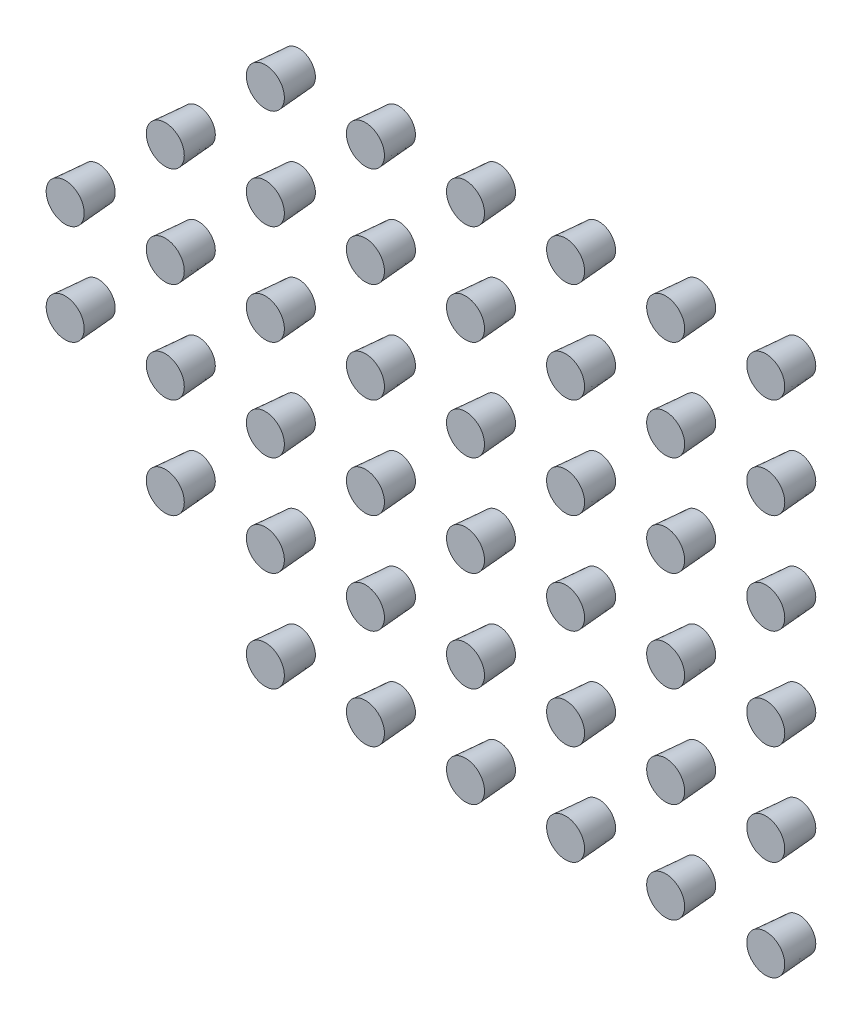
from build123d import *

# Parameters (mm, degrees)
SKETCH_1_R               = 0.5
EXTRUDE_1_DEPTH          = 1
EXTRUDE_1_TAPER          = -4
PATTERN_LINEAR_1_COUNT   = 6
PATTERN_LINEAR_1_PITCH   = 3
PATTERN_LINEAR_1_2_COUNT = 6
PATTERN_LINEAR_1_2_PITCH = 3
PATTERN_LINEAR_2_COUNT   = 2
PATTERN_LINEAR_2_PITCH   = 3
PATTERN_LINEAR_3_COUNT   = 2
PATTERN_LINEAR_3_PITCH   = 3


with BuildPart() as part:
    # 草图1 → 凸台-拉伸1 (new body)
    with BuildSketch(Plane.XY):
        Circle(SKETCH_1_R)
    extrude(amount=EXTRUDE_1_DEPTH, taper=EXTRUDE_1_TAPER)


with BuildPart() as pattern_linear_1_1:
    # 阵列(线性)1: pattern copy
    add(part.part.moved(Location(Vector(0, 1, 0) * (1 * PATTERN_LINEAR_1_PITCH))))


with BuildPart() as pattern_linear_1_2:
    # 阵列(线性)1: pattern copy
    add(part.part.moved(Location(Vector(0, 1, 0) * (2 * PATTERN_LINEAR_1_PITCH))))


with BuildPart() as pattern_linear_1_3:
    # 阵列(线性)1: pattern copy
    add(part.part.moved(Location(Vector(0, 1, 0) * (3 * PATTERN_LINEAR_1_PITCH))))


with BuildPart() as pattern_linear_1_4:
    # 阵列(线性)1: pattern copy
    add(part.part.moved(Location(Vector(0, 1, 0) * (4 * PATTERN_LINEAR_1_PITCH))))


with BuildPart() as pattern_linear_1_5:
    # 阵列(线性)1: pattern copy
    add(part.part.moved(Location(Vector(0, 1, 0) * (5 * PATTERN_LINEAR_1_PITCH))))


with BuildPart() as pattern_linear_1_2_1:
    # Pattern Linear 1 2: pattern copy
    add(part.part.moved(Location(Vector(1, 0, 0) * (1 * PATTERN_LINEAR_1_2_PITCH))))


with BuildPart() as pattern_linear_1_2_2:
    # Pattern Linear 1 2: pattern copy
    add(part.part.moved(Location(Vector(1, 0, 0) * (2 * PATTERN_LINEAR_1_2_PITCH))))


with BuildPart() as pattern_linear_1_2_3:
    # Pattern Linear 1 2: pattern copy
    add(part.part.moved(Location(Vector(1, 0, 0) * (3 * PATTERN_LINEAR_1_2_PITCH))))


with BuildPart() as pattern_linear_1_2_4:
    # Pattern Linear 1 2: pattern copy
    add(part.part.moved(Location(Vector(1, 0, 0) * (4 * PATTERN_LINEAR_1_2_PITCH))))


with BuildPart() as pattern_linear_1_2_5:
    # Pattern Linear 1 2: pattern copy
    add(part.part.moved(Location(Vector(1, 0, 0) * (5 * PATTERN_LINEAR_1_2_PITCH))))


with BuildPart() as pattern_linear_1_2_6:
    # Pattern Linear 1 2: pattern copy
    add(pattern_linear_1_1.part.moved(Location(Vector(1, 0, 0) * (1 * PATTERN_LINEAR_1_2_PITCH))))


with BuildPart() as pattern_linear_1_2_7:
    # Pattern Linear 1 2: pattern copy
    add(pattern_linear_1_1.part.moved(Location(Vector(1, 0, 0) * (2 * PATTERN_LINEAR_1_2_PITCH))))


with BuildPart() as pattern_linear_1_2_8:
    # Pattern Linear 1 2: pattern copy
    add(pattern_linear_1_1.part.moved(Location(Vector(1, 0, 0) * (3 * PATTERN_LINEAR_1_2_PITCH))))


with BuildPart() as pattern_linear_1_2_9:
    # Pattern Linear 1 2: pattern copy
    add(pattern_linear_1_1.part.moved(Location(Vector(1, 0, 0) * (4 * PATTERN_LINEAR_1_2_PITCH))))


with BuildPart() as pattern_linear_1_2_10:
    # Pattern Linear 1 2: pattern copy
    add(pattern_linear_1_1.part.moved(Location(Vector(1, 0, 0) * (5 * PATTERN_LINEAR_1_2_PITCH))))


with BuildPart() as pattern_linear_1_2_11:
    # Pattern Linear 1 2: pattern copy
    add(pattern_linear_1_2.part.moved(Location(Vector(1, 0, 0) * (1 * PATTERN_LINEAR_1_2_PITCH))))


with BuildPart() as pattern_linear_1_2_12:
    # Pattern Linear 1 2: pattern copy
    add(pattern_linear_1_2.part.moved(Location(Vector(1, 0, 0) * (2 * PATTERN_LINEAR_1_2_PITCH))))


with BuildPart() as pattern_linear_1_2_13:
    # Pattern Linear 1 2: pattern copy
    add(pattern_linear_1_2.part.moved(Location(Vector(1, 0, 0) * (3 * PATTERN_LINEAR_1_2_PITCH))))


with BuildPart() as pattern_linear_1_2_14:
    # Pattern Linear 1 2: pattern copy
    add(pattern_linear_1_2.part.moved(Location(Vector(1, 0, 0) * (4 * PATTERN_LINEAR_1_2_PITCH))))


with BuildPart() as pattern_linear_1_2_15:
    # Pattern Linear 1 2: pattern copy
    add(pattern_linear_1_2.part.moved(Location(Vector(1, 0, 0) * (5 * PATTERN_LINEAR_1_2_PITCH))))


with BuildPart() as pattern_linear_1_2_16:
    # Pattern Linear 1 2: pattern copy
    add(pattern_linear_1_3.part.moved(Location(Vector(1, 0, 0) * (1 * PATTERN_LINEAR_1_2_PITCH))))


with BuildPart() as pattern_linear_1_2_17:
    # Pattern Linear 1 2: pattern copy
    add(pattern_linear_1_3.part.moved(Location(Vector(1, 0, 0) * (2 * PATTERN_LINEAR_1_2_PITCH))))


with BuildPart() as pattern_linear_1_2_18:
    # Pattern Linear 1 2: pattern copy
    add(pattern_linear_1_3.part.moved(Location(Vector(1, 0, 0) * (3 * PATTERN_LINEAR_1_2_PITCH))))


with BuildPart() as pattern_linear_1_2_19:
    # Pattern Linear 1 2: pattern copy
    add(pattern_linear_1_3.part.moved(Location(Vector(1, 0, 0) * (4 * PATTERN_LINEAR_1_2_PITCH))))


with BuildPart() as pattern_linear_1_2_20:
    # Pattern Linear 1 2: pattern copy
    add(pattern_linear_1_3.part.moved(Location(Vector(1, 0, 0) * (5 * PATTERN_LINEAR_1_2_PITCH))))


with BuildPart() as pattern_linear_1_2_21:
    # Pattern Linear 1 2: pattern copy
    add(pattern_linear_1_4.part.moved(Location(Vector(1, 0, 0) * (1 * PATTERN_LINEAR_1_2_PITCH))))


with BuildPart() as pattern_linear_1_2_22:
    # Pattern Linear 1 2: pattern copy
    add(pattern_linear_1_4.part.moved(Location(Vector(1, 0, 0) * (2 * PATTERN_LINEAR_1_2_PITCH))))


with BuildPart() as pattern_linear_1_2_23:
    # Pattern Linear 1 2: pattern copy
    add(pattern_linear_1_4.part.moved(Location(Vector(1, 0, 0) * (3 * PATTERN_LINEAR_1_2_PITCH))))


with BuildPart() as pattern_linear_1_2_24:
    # Pattern Linear 1 2: pattern copy
    add(pattern_linear_1_4.part.moved(Location(Vector(1, 0, 0) * (4 * PATTERN_LINEAR_1_2_PITCH))))


with BuildPart() as pattern_linear_1_2_25:
    # Pattern Linear 1 2: pattern copy
    add(pattern_linear_1_4.part.moved(Location(Vector(1, 0, 0) * (5 * PATTERN_LINEAR_1_2_PITCH))))


with BuildPart() as pattern_linear_1_2_26:
    # Pattern Linear 1 2: pattern copy
    add(pattern_linear_1_5.part.moved(Location(Vector(1, 0, 0) * (1 * PATTERN_LINEAR_1_2_PITCH))))


with BuildPart() as pattern_linear_1_2_27:
    # Pattern Linear 1 2: pattern copy
    add(pattern_linear_1_5.part.moved(Location(Vector(1, 0, 0) * (2 * PATTERN_LINEAR_1_2_PITCH))))


with BuildPart() as pattern_linear_1_2_28:
    # Pattern Linear 1 2: pattern copy
    add(pattern_linear_1_5.part.moved(Location(Vector(1, 0, 0) * (3 * PATTERN_LINEAR_1_2_PITCH))))


with BuildPart() as pattern_linear_1_2_29:
    # Pattern Linear 1 2: pattern copy
    add(pattern_linear_1_5.part.moved(Location(Vector(1, 0, 0) * (4 * PATTERN_LINEAR_1_2_PITCH))))


with BuildPart() as pattern_linear_1_2_30:
    # Pattern Linear 1 2: pattern copy
    add(pattern_linear_1_5.part.moved(Location(Vector(1, 0, 0) * (5 * PATTERN_LINEAR_1_2_PITCH))))


with BuildPart() as pattern_linear_2_1:
    # 阵列(线性)2: pattern copy
    add(pattern_linear_1_4.part.moved(Location(Vector(-1, 0, 0) * (1 * PATTERN_LINEAR_2_PITCH))))


with BuildPart() as pattern_linear_2_2:
    # 阵列(线性)2: pattern copy
    add(pattern_linear_1_3.part.moved(Location(Vector(-1, 0, 0) * (1 * PATTERN_LINEAR_2_PITCH))))


with BuildPart() as pattern_linear_2_3:
    # 阵列(线性)2: pattern copy
    add(pattern_linear_1_2.part.moved(Location(Vector(-1, 0, 0) * (1 * PATTERN_LINEAR_2_PITCH))))


with BuildPart() as pattern_linear_2_4:
    # 阵列(线性)2: pattern copy
    add(pattern_linear_1_1.part.moved(Location(Vector(-1, 0, 0) * (1 * PATTERN_LINEAR_2_PITCH))))


with BuildPart() as pattern_linear_3_1:
    # 阵列(线性)3: pattern copy
    add(pattern_linear_2_2.part.moved(Location(Vector(-1, 0, 0) * (1 * PATTERN_LINEAR_3_PITCH))))


with BuildPart() as pattern_linear_3_2:
    # 阵列(线性)3: pattern copy
    add(pattern_linear_2_3.part.moved(Location(Vector(-1, 0, 0) * (1 * PATTERN_LINEAR_3_PITCH))))


solid = Compound([part.part, pattern_linear_1_1.part, pattern_linear_1_2.part, pattern_linear_1_3.part, pattern_linear_1_4.part, pattern_linear_1_5.part, pattern_linear_1_2_1.part, pattern_linear_1_2_2.part, pattern_linear_1_2_3.part, pattern_linear_1_2_4.part, pattern_linear_1_2_5.part, pattern_linear_1_2_6.part, pattern_linear_1_2_7.part, pattern_linear_1_2_8.part, pattern_linear_1_2_9.part, pattern_linear_1_2_10.part, pattern_linear_1_2_11.part, pattern_linear_1_2_12.part, pattern_linear_1_2_13.part, pattern_linear_1_2_14.part, pattern_linear_1_2_15.part, pattern_linear_1_2_16.part, pattern_linear_1_2_17.part, pattern_linear_1_2_18.part, pattern_linear_1_2_19.part, pattern_linear_1_2_20.part, pattern_linear_1_2_21.part, pattern_linear_1_2_22.part, pattern_linear_1_2_23.part, pattern_linear_1_2_24.part, pattern_linear_1_2_25.part, pattern_linear_1_2_26.part, pattern_linear_1_2_27.part, pattern_linear_1_2_28.part, pattern_linear_1_2_29.part, pattern_linear_1_2_30.part, pattern_linear_2_1.part, pattern_linear_2_2.part, pattern_linear_2_3.part, pattern_linear_2_4.part, pattern_linear_3_1.part, pattern_linear_3_2.part])
